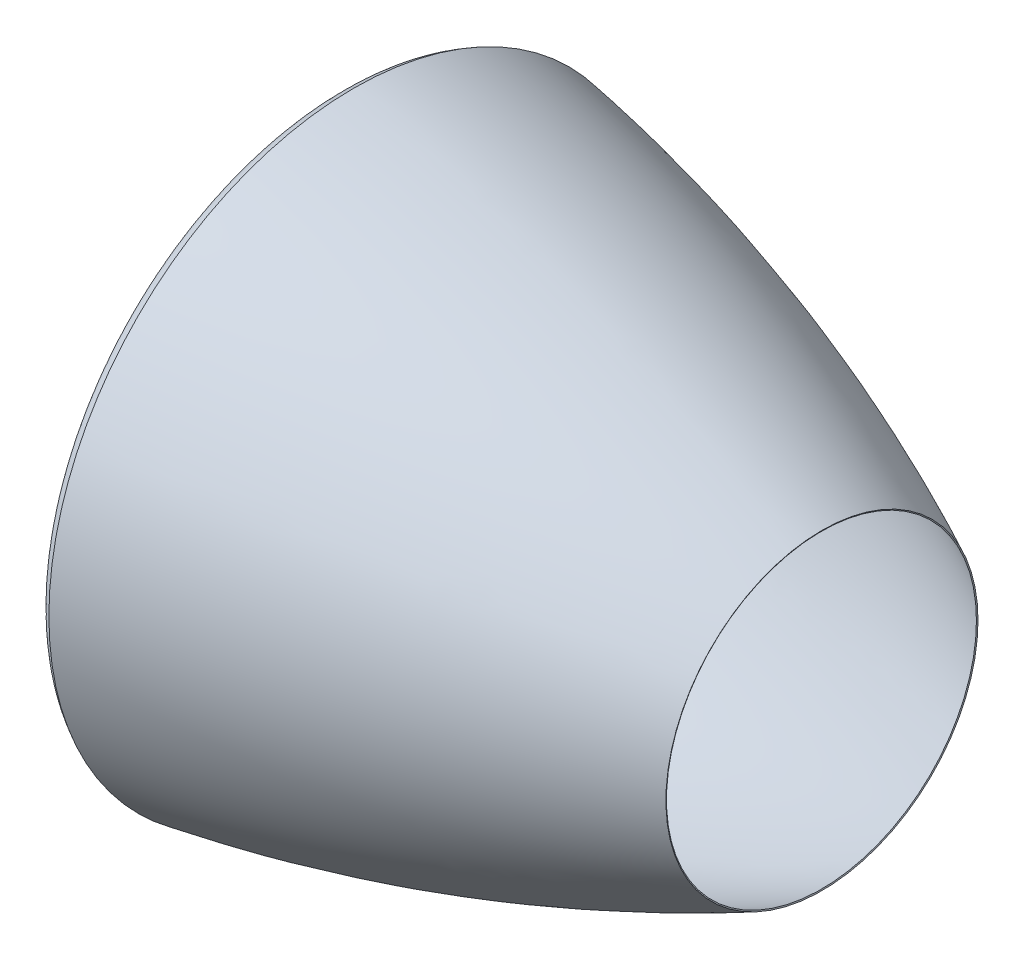
from build123d import *

# Parameters (mm, degrees)
THICKEN1_T1 = 5


with BuildPart() as body_1:
    # Surface-Revolve1: a surface, the sketch's curves turned about an axis
    with BuildLine(Plane.XY, mode=Mode.PRIVATE) as surface_revolve1_1_path:
        Line((58.164522356, 1250), (33.164522356, 1250))
        Line((33.164522356, 1250), (25, 1200))
        Line((25, 1200), (0, 1200))
        add(Edge.make_bspline(
            [(0, 1200), (-95.586509213, 1249.979284162), (0, 1298.708862894)],
            knots=[0, 0, 0, 1, 1, 1], degree=2))
        add(Edge.make_bspline(
            [(0, 1298.708862894), (1038.411463124, 1129.058374243), (2000, 663)],
            knots=[0, 0, 0, 1, 1, 1], degree=2))
    surface_revolve1_1 = Shell.revolve(surface_revolve1_1_path.wire(), 360, Axis((0, 0, 0), (1, 0, 0)))
    add(Solid.thicken(surface_revolve1_1, THICKEN1_T1))


solid = body_1.part
